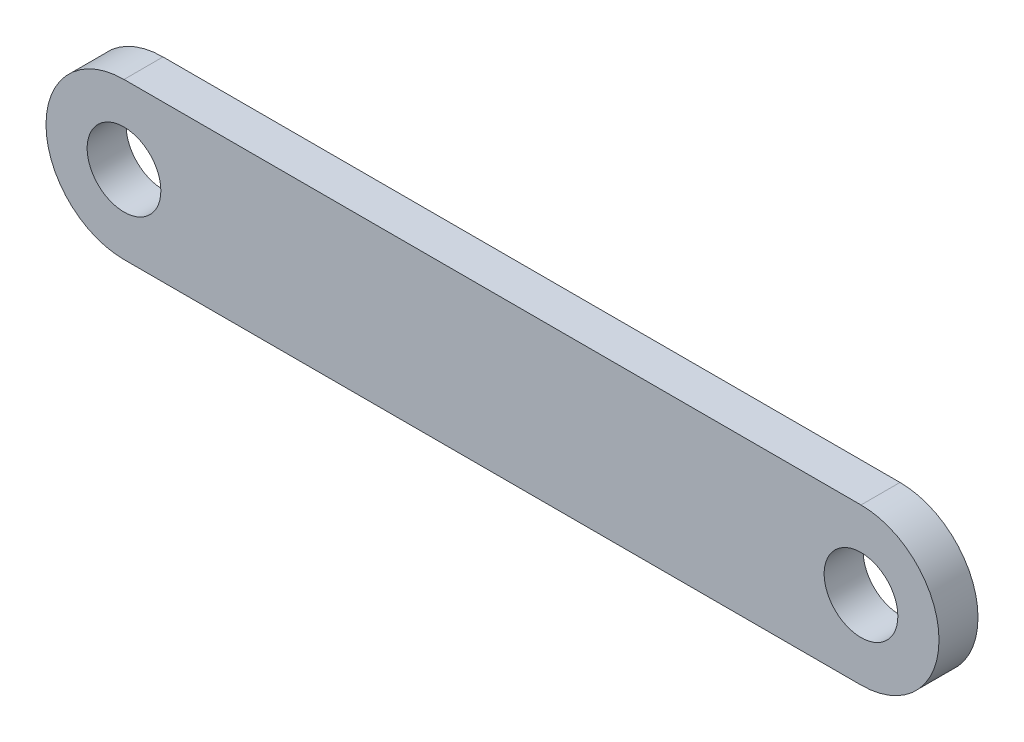
from build123d import *

# Parameters (mm, degrees)
SKETCH1_R      = 3
EXTRUDE1_DEPTH = 3.175


with BuildPart() as part:
    # Sketch1 → Extrude1 (new body)
    with BuildSketch(Plane.XY):
        with BuildLine():
            Line((60, 6.35), (0, 6.35))
            ThreePointArc((0, 6.35), (-6.35, 0), (0, -6.35))
            Line((0, -6.35), (60, -6.35))
            ThreePointArc((60, -6.35), (66.35, 0), (60, 6.35))
        make_face()
        Circle(SKETCH1_R, mode=Mode.SUBTRACT)
        with Locations((60, 0)):
            Circle(SKETCH1_R, mode=Mode.SUBTRACT)
    extrude(amount=-EXTRUDE1_DEPTH)


solid = part.part
